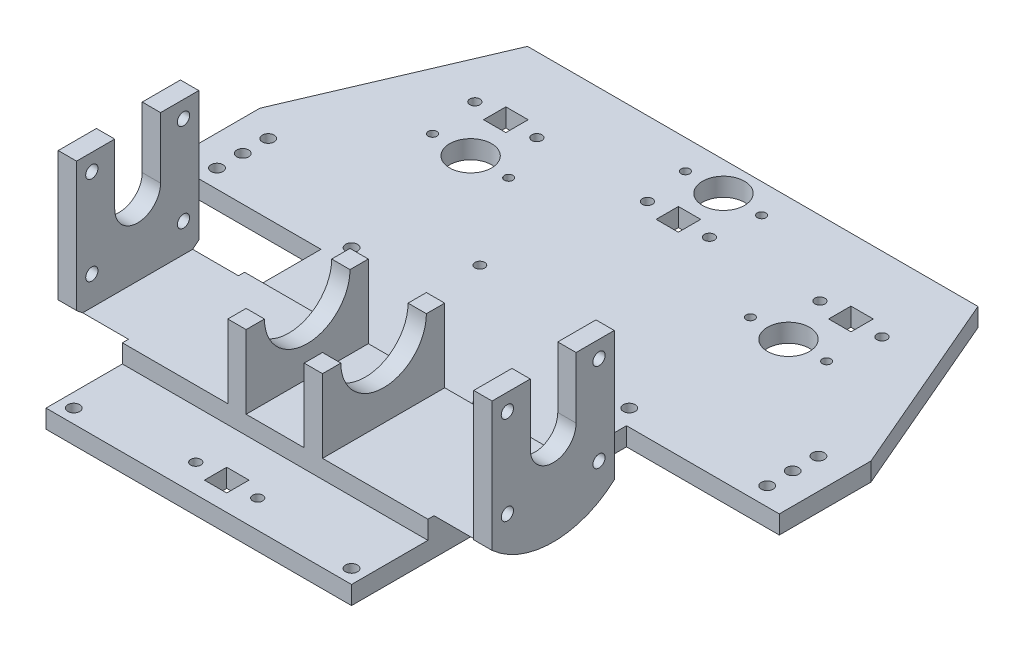
from build123d import *

# Parameters (mm, degrees)
SALIENTE_EXTRUIR1_DEPTH     = 6
CROQUIS2_W                  = 6
CROQUIS2_H                  = 40
SALIENTE_EXTRUIR2_DEPTH     = 50
CORTAR_EXTRUIR1_REACH       = 210.447
CROQUIS3_R                  = 2
CROQUIS4_W                  = 31
CROQUIS4_H                  = 40
SALIENTE_EXTRUIR3_DEPTH     = 30
CORTAR_EXTRUIR2_REACH       = 177.525
CROQUIS5_W                  = 19
CROQUIS5_H                  = 24
CORTAR_EXTRUIR3_DEPTH       = 31
CORTAR_EXTRUIR4_REACH       = 148.714
CORTAR_EXTRUIR5_DEPTH       = 21
CORTAR_EXTRUIR6_DEPTH       = 21
SALIENTE_EXTRUIR8_DEPTH     = 80.5
CORTAR_EXTRUIR7_DEPTH       = 15
CROQUIS18_R                 = 1.95
CORTAR_EXTRUIR31_DEPTH      = 17.5
CROQUIS19_R                 = 3.25
CORTAR_EXTRUIR32_DEPTH      = 2.2
CROQUIS21_R                 = 1.95
CORTAR_EXTRUIR33_DEPTH      = 17.5
CROQUIS22_R                 = 3.25
CORTAR_EXTRUIR34_DEPTH      = 2.2
CROQUIS24_W                 = 8.67512497
CROQUIS24_H                 = 6
CORTAR_EXTRUIR36_DEPTH      = 313.226607494
CORTAR_EXTRUIR36_DEPTH_BACK = 313.226607494
CROQUIS29_R                 = 1.95
CORTAR_EXTRUIR38_DEPTH      = 6
CROQUIS30_R                 = 3.25
CORTAR_EXTRUIR39_DEPTH      = 2.2
CROQUIS33_W                 = 7.3
CROQUIS33_H                 = 7.3
CORTAR_EXTRUIR42_DEPTH      = 6
CROQUIS34_R                 = 1.65
CORTAR_EXTRUIR43_DEPTH      = 5
CROQUIS35_R                 = 6.875
CORTAR_EXTRUIR44_DEPTH      = 6
CROQUIS38_R                 = 1.6
CORTAR_EXTRUIR46_DEPTH      = 4.5
CROQUIS39_R                 = 1.4
CORTAR_EXTRUIR47_DEPTH      = 6


with BuildPart() as part:
    # Croquis1 → Saliente-Extruir1 (new body)
    with BuildSketch(Plane(origin=(0, 16, 0), x_dir=(1, 0, 0), z_dir=(0, 1, 0))):
        Polygon((100, 95), (-100, 95), (-100, -5), (-50, -5), (-50, -30), (-71, -30), (-71, -70), (-50, -70), (-50, -95), (50, -95), (50, -70), (71, -70), (71, -30), (50, -30), (50, -5), (100, -5), align=None)
    extrude(amount=SALIENTE_EXTRUIR1_DEPTH)

    # Croquis2 → Saliente-Extruir2 (add)
    with BuildSketch(Plane(origin=(0, 22, 0), x_dir=(1, 0, 0), z_dir=(0, 1, 0))):
        with Locations((-68, -50)):
            Rectangle(CROQUIS2_W, CROQUIS2_H)
        with Locations((68, -50)):
            Rectangle(CROQUIS2_W, CROQUIS2_H)
    extrude(amount=SALIENTE_EXTRUIR2_DEPTH)

    # Croquis3 → Cortar-Extruir1 (cut, up to next)
    with BuildSketch(Plane.ZY.offset(71), mode=Mode.PRIVATE) as cortar_extruir1_sk1:
        with Locations((35, 66.5)):
            Circle(CROQUIS3_R)
    cortar_extruir1_tool1 = extrude(cortar_extruir1_sk1.sketch, amount=-CORTAR_EXTRUIR1_REACH, mode=Mode.PRIVATE) & part.part
    # Croquis3 → Cortar-Extruir1 (cut, up to next)
    with BuildSketch(Plane.ZY.offset(71), mode=Mode.PRIVATE) as cortar_extruir1_sk2:
        with Locations((35, 37.5)):
            Circle(CROQUIS3_R)
    cortar_extruir1_tool2 = extrude(cortar_extruir1_sk2.sketch, amount=-CORTAR_EXTRUIR1_REACH, mode=Mode.PRIVATE) & part.part
    # Croquis3 → Cortar-Extruir1 (cut, up to next)
    with BuildSketch(Plane.ZY.offset(71), mode=Mode.PRIVATE) as cortar_extruir1_sk3:
        with Locations((65, 66.5)):
            Circle(CROQUIS3_R)
    cortar_extruir1_tool3 = extrude(cortar_extruir1_sk3.sketch, amount=-CORTAR_EXTRUIR1_REACH, mode=Mode.PRIVATE) & part.part
    # Croquis3 → Cortar-Extruir1 (cut, up to next)
    with BuildSketch(Plane.ZY.offset(71), mode=Mode.PRIVATE) as cortar_extruir1_sk4:
        with Locations((65, 37.5)):
            Circle(CROQUIS3_R)
    cortar_extruir1_tool4 = extrude(cortar_extruir1_sk4.sketch, amount=-CORTAR_EXTRUIR1_REACH, mode=Mode.PRIVATE) & part.part
    # Croquis3 → Cortar-Extruir1 (cut, up to next)
    with BuildSketch(Plane.ZY.offset(71), mode=Mode.PRIVATE) as cortar_extruir1_sk5:
        with BuildLine():
            Line((57.5, 72), (42.5, 72))
            Line((42.5, 72), (42.5, 52))
            ThreePointArc((42.5, 52), (50, 44.5), (57.5, 52))
            Line((57.5, 52), (57.5, 72))
        make_face()
    cortar_extruir1_tool5 = extrude(cortar_extruir1_sk5.sketch, amount=-CORTAR_EXTRUIR1_REACH, mode=Mode.PRIVATE) & part.part
    cortar_extruir1_1 = cortar_extruir1_tool1.solids().sort_by_distance((-71, 66.5, 35))[0]
    add(cortar_extruir1_1, mode=Mode.SUBTRACT)
    cortar_extruir1_2 = cortar_extruir1_tool2.solids().sort_by_distance((-71, 37.5, 35))[0]
    add(cortar_extruir1_2, mode=Mode.SUBTRACT)
    cortar_extruir1_3 = cortar_extruir1_tool3.solids().sort_by_distance((-71, 66.5, 65))[0]
    add(cortar_extruir1_3, mode=Mode.SUBTRACT)
    cortar_extruir1_4 = cortar_extruir1_tool4.solids().sort_by_distance((-71, 37.5, 65))[0]
    add(cortar_extruir1_4, mode=Mode.SUBTRACT)
    cortar_extruir1_5 = cortar_extruir1_tool5.solids().sort_by_distance((-71, 59.000641, 50))[0]
    add(cortar_extruir1_5, mode=Mode.SUBTRACT)
    cortar_extruir1 = cortar_extruir1_1 + cortar_extruir1_2 + cortar_extruir1_3 + cortar_extruir1_4 + cortar_extruir1_5  # Cortar-Extruir1 as one shape, for the pattern or mirror that repeats it

    # Simetr_a1: Cortar-Extruir1 across plane
    add(cortar_extruir1.mirror(Plane(origin=(0, 0, 0), x_dir=(0, 0, 1), z_dir=(1, 0, 0))), mode=Mode.SUBTRACT)

    # Croquis4 → Saliente-Extruir3 (add)
    with BuildSketch(Plane(origin=(0, 22, 0), x_dir=(1, 0, 0), z_dir=(0, 1, 0))):
        with Locations((0, -50)):
            Rectangle(CROQUIS4_W, CROQUIS4_H)
    extrude(amount=SALIENTE_EXTRUIR3_DEPTH)

    # Croquis5 → Cortar-Extruir2 (cut, up to next)
    with BuildSketch(Plane(origin=(0, 0, 30), x_dir=(-1, 0, 0), z_dir=(0, 0, -1)), mode=Mode.PRIVATE) as cortar_extruir2_sk1:
        with Locations((0, 40)):
            Rectangle(CROQUIS5_W, CROQUIS5_H)
    cortar_extruir2_tool1 = extrude(cortar_extruir2_sk1.sketch, amount=-CORTAR_EXTRUIR2_REACH, mode=Mode.PRIVATE) & part.part
    add(cortar_extruir2_tool1.solids().sort_by_distance((0, 40, 30))[0], mode=Mode.SUBTRACT)

    # Croquis6 → Cortar-Extruir3 (cut)
    with BuildSketch(Plane(origin=(15.5, 0, 0), x_dir=(0, 0, -1), z_dir=(1, 0, 0))):
        with BuildLine():
            Line((-64, 52), (-36, 52))
            ThreePointArc((-36, 52), (-50, 38), (-64, 52))
        make_face()
    extrude(amount=-CORTAR_EXTRUIR3_DEPTH, mode=Mode.SUBTRACT)

    # Croquis9 → Cortar-Extruir4 (cut, up to next)
    with BuildSketch(Plane(origin=(0, 22, 0), x_dir=(1, 0, 0), z_dir=(0, 1, 0)), mode=Mode.PRIVATE) as cortar_extruir4_sk1:
        Polygon((100, 25), (70, 95), (100, 95), align=None)
    cortar_extruir4_tool1 = extrude(cortar_extruir4_sk1.sketch, amount=-CORTAR_EXTRUIR4_REACH, mode=Mode.PRIVATE) & part.part
    # Croquis9 → Cortar-Extruir4 (cut, up to next)
    with BuildSketch(Plane(origin=(0, 22, 0), x_dir=(1, 0, 0), z_dir=(0, 1, 0)), mode=Mode.PRIVATE) as cortar_extruir4_sk2:
        Polygon((-70, 95), (-100, 95), (-100, 25), align=None)
    cortar_extruir4_tool2 = extrude(cortar_extruir4_sk2.sketch, amount=-CORTAR_EXTRUIR4_REACH, mode=Mode.PRIVATE) & part.part
    add(cortar_extruir4_tool1.solids().sort_by_distance((90, 22, -71.666667))[0], mode=Mode.SUBTRACT)
    add(cortar_extruir4_tool2.solids().sort_by_distance((-90, 22, -71.666667))[0], mode=Mode.SUBTRACT)

    # Croquis10 → Cortar-Extruir5 (cut)
    with BuildSketch(Plane.ZY.offset(71)):
        with BuildLine():
            Line((70, 16), (70, 17.358983849))
            ThreePointArc((70, 17.358983849), (68.730127256, 16.65622639), (67.435595774, 16))
            Line((67.435595774, 16), (70, 16))
        make_face()
        with BuildLine():
            ThreePointArc((32.564404226, 16), (31.269872744, 16.65622639), (30, 17.358983849))
            Line((30, 17.358983849), (30, 16))
            Line((30, 16), (32.564404226, 16))
        make_face()
        with BuildLine():
            Line((30, 25.751190503), (30, 17.358983849))
            ThreePointArc((30, 17.358983849), (31.269872744, 16.65622639), (32.564404226, 16))
            Line((32.564404226, 16), (67.435595774, 16))
            ThreePointArc((67.435595774, 16), (68.730127256, 16.65622639), (70, 17.358983849))
            Line((70, 17.358983849), (70, 25.751190503))
            ThreePointArc((70, 25.751190503), (50, 19), (30, 25.751190503))
        make_face()
        with BuildLine():
            Line((30, 29.639320225), (30, 25.751190503))
            ThreePointArc((30, 25.751190503), (50, 19), (70, 25.751190503))
            Line((70, 25.751190503), (70, 29.639320225))
            ThreePointArc((70, 29.639320225), (50, 22), (30, 29.639320225))
        make_face()
        with BuildLine():
            ThreePointArc((83, 52), (35.354181484, 81.571946165), (30, 25.751190503))
            Line((30, 25.751190503), (30, 29.639320225))
            ThreePointArc((30, 29.639320225), (37.752551286, 79.386127875), (80, 52))
            ThreePointArc((80, 52), (77.386127875, 39.752551286), (70, 29.639320225))
            Line((70, 29.639320225), (70, 25.751190503))
            ThreePointArc((70, 25.751190503), (79.571946165, 37.354181484), (83, 52))
        make_face()
        with BuildLine():
            Line((30, 29.639320225), (30, 25.751190503))
            ThreePointArc((30, 25.751190503), (50, 19), (70, 25.751190503))
            Line((70, 25.751190503), (70, 29.639320225))
            ThreePointArc((70, 29.639320225), (50, 22), (30, 29.639320225))
        make_face()
        with BuildLine():
            ThreePointArc((83, 52), (35.354181484, 81.571946165), (30, 25.751190503))
            Line((30, 25.751190503), (30, 29.639320225))
            ThreePointArc((30, 29.639320225), (37.752551286, 79.386127875), (80, 52))
            ThreePointArc((80, 52), (77.386127875, 39.752551286), (70, 29.639320225))
            Line((70, 29.639320225), (70, 25.751190503))
            ThreePointArc((70, 25.751190503), (79.571946165, 37.354181484), (83, 52))
        make_face()
    extrude(amount=-CORTAR_EXTRUIR5_DEPTH, mode=Mode.SUBTRACT)


with BuildPart() as cortar_extruir5_piece_1:
    # of the separate pieces the step leaves, piece 1, a body of its own (cortar_extruir5_pieces)
    add(part.part.solids().sort_by_distance((50, 16, 95))[0])

    # Croquis11 → Cortar-Extruir6 (cut)
    with BuildSketch(Plane(origin=(71, 0, 0), x_dir=(0, 0, -1), z_dir=(1, 0, 0))):
        with BuildLine():
            ThreePointArc((-67.435595774, 16), (-68.730127256, 16.65622639), (-70, 17.358983849))
            Line((-70, 17.358983849), (-70, 16))
            Line((-70, 16), (-67.435595774, 16))
        make_face()
        with BuildLine():
            ThreePointArc((-20, 52), (-22.613872125, 39.752551286), (-30, 29.639320225))
            Line((-30, 29.639320225), (-30, 25.751190503))
            ThreePointArc((-30, 25.751190503), (-20.428053835, 37.354181484), (-17, 52))
            ThreePointArc((-17, 52), (-64.645818516, 81.571946165), (-70, 25.751190503))
            Line((-70, 25.751190503), (-70, 29.639320225))
            ThreePointArc((-70, 29.639320225), (-62.247448714, 79.386127875), (-20, 52))
        make_face()
        with BuildLine():
            Line((-30, 25.751190503), (-30, 29.639320225))
            ThreePointArc((-30, 29.639320225), (-50, 22), (-70, 29.639320225))
            Line((-70, 29.639320225), (-70, 25.751190503))
            ThreePointArc((-70, 25.751190503), (-50, 19), (-30, 25.751190503))
        make_face()
        with BuildLine():
            Line((-30, 17.358983849), (-30, 25.751190503))
            ThreePointArc((-30, 25.751190503), (-50, 19), (-70, 25.751190503))
            Line((-70, 25.751190503), (-70, 17.358983849))
            ThreePointArc((-70, 17.358983849), (-68.730127256, 16.65622639), (-67.435595774, 16))
            Line((-67.435595774, 16), (-32.564404226, 16))
            ThreePointArc((-32.564404226, 16), (-31.269872744, 16.65622639), (-30, 17.358983849))
        make_face()
        with BuildLine():
            Line((-30, 16), (-30, 17.358983849))
            ThreePointArc((-30, 17.358983849), (-31.269872744, 16.65622639), (-32.564404226, 16))
            Line((-32.564404226, 16), (-30, 16))
        make_face()
    extrude(amount=-CORTAR_EXTRUIR6_DEPTH, mode=Mode.SUBTRACT)


with BuildPart() as cortar_extruir5_piece_2:
    # of the separate pieces the step leaves, piece 2, a body of its own (cortar_extruir5_pieces)
    add(part.part.solids().sort_by_distance((-71, 29.639320225, 70))[0])



with BuildPart() as cortar_extruir6_piece_1:
    # of the separate pieces the step leaves, piece 1, a body of its own (cortar_extruir6_pieces)
    add(cortar_extruir5_piece_1.part.solids().sort_by_distance((50, 16, 95))[0])


with BuildPart() as cortar_extruir6_piece_2:
    # of the separate pieces the step leaves, piece 2, a body of its own (cortar_extruir6_pieces)
    add(cortar_extruir5_piece_1.part.solids().sort_by_distance((71, 29.639320225, 70))[0])


with BuildPart() as cortar_extruir5_piece_2_1:
    add(cortar_extruir5_piece_2.part)

    add(cortar_extruir6_piece_1.part)  # Saliente-Extruir8 merges Cortar-Extruir6 piece 1
    # Croquis13 → Saliente-Extruir8 (add)
    with BuildSketch(Plane(origin=(-65, 0, 0), x_dir=(0, 0, -1), z_dir=(1, 0, 0))):
        with BuildLine():
            Line((-68, 28), (-70, 28))
            Line((-70, 28), (-70, 22))
            Line((-70, 22), (-50, 22))
            ThreePointArc((-50, 22), (-59.486832981, 23.539501058), (-68, 28))
        make_face()
        with BuildLine():
            Line((-32, 28), (-68, 28))
            ThreePointArc((-68, 28), (-59.486832981, 23.539501058), (-50, 22))
            ThreePointArc((-50, 22), (-40.513167019, 23.539501058), (-32, 28))
        make_face()
        with BuildLine():
            Line((-30, 22), (-30, 28))
            Line((-30, 28), (-32, 28))
            ThreePointArc((-32, 28), (-40.513167019, 23.539501058), (-50, 22))
            Line((-50, 22), (-30, 22))
        make_face()
    saliente_extruir8 = extrude(amount=SALIENTE_EXTRUIR8_DEPTH)

    # Simetr_a10: Saliente-Extruir8 across plane
    add(saliente_extruir8.mirror(Plane(origin=(0, 0, 0), x_dir=(0, 0, 1), z_dir=(1, 0, 0))))

    # Croquis14 → Cortar-Extruir7 (cut)
    with BuildSketch(Plane.ZY.offset(65)):
        with BuildLine():
            Line((70, 22), (70, 28))
            Line((70, 28), (68, 28))
            ThreePointArc((68, 28), (59.486832981, 23.539501058), (50, 22))
            Line((50, 22), (70, 22))
        make_face()
        with BuildLine():
            Line((30, 22), (50, 22))
            ThreePointArc((50, 22), (40.513167019, 23.539501058), (32, 28))
            Line((32, 28), (30, 28))
            Line((30, 28), (30, 22))
        make_face()
    cortar_extruir7 = extrude(amount=-CORTAR_EXTRUIR7_DEPTH, mode=Mode.SUBTRACT)

    # Simetr_a12: Cortar-Extruir7 across plane
    add(cortar_extruir7.mirror(Plane(origin=(0, 0, 0), x_dir=(0, 0, 1), z_dir=(1, 0, 0))), mode=Mode.SUBTRACT)

    # Croquis18 → Cortar-Extruir31 (cut)
    with BuildSketch(Plane.XZ.offset(-16)):
        with Locations(Location((-45.45, 90.45, 0), (0, 0, 270))):
            Circle(CROQUIS18_R)
    cortar_extruir31 = extrude(amount=-CORTAR_EXTRUIR31_DEPTH, mode=Mode.SUBTRACT)

    # Croquis19 → Cortar-Extruir32 (cut)
    with BuildSketch(Plane.XZ.offset(-16)):
        with Locations(Location((-45.45, 90.45, 0), (0, 0, 270))):
            Circle(CROQUIS19_R)
    cortar_extruir32 = extrude(amount=-CORTAR_EXTRUIR32_DEPTH, mode=Mode.SUBTRACT)

    # Simetr_a13: Cortar-Extruir31, Cortar-Extruir32 across plane
    add(cortar_extruir31.mirror(Plane(origin=(0, 0, 0), x_dir=(0, 0, 1), z_dir=(1, 0, 0))), mode=Mode.SUBTRACT)
    add(cortar_extruir32.mirror(Plane(origin=(0, 0, 0), x_dir=(0, 0, 1), z_dir=(1, 0, 0))), mode=Mode.SUBTRACT)

    # Croquis21 → Cortar-Extruir33 (cut)
    with BuildSketch(Plane.XZ.offset(-16)):
        with Locations(Location((45.45, -0.45, 0), (0, 0, 270))):
            Circle(CROQUIS21_R)
        with Locations(Location((-45.45, -0.45, 0), (0, 0, 270))):
            Circle(CROQUIS21_R)
    extrude(amount=-CORTAR_EXTRUIR33_DEPTH, mode=Mode.SUBTRACT)

    # Croquis22 → Cortar-Extruir34 (cut)
    with BuildSketch(Plane.XZ.offset(-16)):
        with Locations(Location((45.45, -0.45, 0), (0, 0, 270))):
            Circle(CROQUIS22_R)
        with Locations(Location((-45.45, -0.45, 0), (0, 0, 270))):
            Circle(CROQUIS22_R)
    extrude(amount=-CORTAR_EXTRUIR34_DEPTH, mode=Mode.SUBTRACT)

    # Croquis24 → Cortar-Extruir36 (cut, two sides)
    with BuildSketch(Plane(origin=(4.580542105, 14.193676317, -193.455878052), x_dir=(0, 0, -1), z_dir=(1, 0, 0))) as cortar_extruir36_sk:
        with Locations((-102.793440537, 4.806323683)):
            Rectangle(CROQUIS24_W, CROQUIS24_H)
    extrude(amount=CORTAR_EXTRUIR36_DEPTH, mode=Mode.SUBTRACT)
    extrude(cortar_extruir36_sk.sketch, amount=-CORTAR_EXTRUIR36_DEPTH_BACK, mode=Mode.SUBTRACT)

    # Croquis29 → Cortar-Extruir38 (cut)
    with BuildSketch(Plane.XZ.offset(-16)):
        with Locations(Location((90.042254279, -17.77, 0), (0, 0, 270))):
            Circle(CROQUIS29_R)
        with Locations(Location((90, -9.385, 0), (0, 0, 270))):
            Circle(CROQUIS29_R)
        with Locations(Location((90.042254279, -1, 0), (0, 0, 270))):
            Circle(CROQUIS29_R)
        with Locations(Location((-90.042254279, -1, 0), (0, 0, 90))):
            Circle(CROQUIS29_R)
        with Locations(Location((-90, -9.385, 0), (0, 0, 90))):
            Circle(CROQUIS29_R)
        with Locations(Location((-90.042254279, -17.77, 0), (0, 0, 90))):
            Circle(CROQUIS29_R)
    extrude(amount=-CORTAR_EXTRUIR38_DEPTH, mode=Mode.SUBTRACT)

    # Croquis30 → Cortar-Extruir39 (cut)
    with BuildSketch(Plane.XZ.offset(-16)):
        with Locations(Location((90.073577236, -1, 0), (0, 0, 270))):
            Circle(CROQUIS30_R)
        with Locations(Location((90, -9.385, 0), (0, 0, 270))):
            Circle(CROQUIS30_R)
        with Locations(Location((90, -17.768453788, 0), (0, 0, 270))):
            Circle(CROQUIS30_R)
        with Locations(Location((-90, -17.768453788, 0), (0, 0, 90))):
            Circle(CROQUIS30_R)
        with Locations(Location((-90, -9.385, 0), (0, 0, 90))):
            Circle(CROQUIS30_R)
        with Locations(Location((-90.073577236, -1, 0), (0, 0, 90))):
            Circle(CROQUIS30_R)
    extrude(amount=-CORTAR_EXTRUIR39_DEPTH, mode=Mode.SUBTRACT)

    # Croquis33 → Cortar-Extruir42 (cut)
    with BuildSketch(Plane(origin=(0, 22, 0), x_dir=(1, 0, 0), z_dir=(0, 1, 0))):
        with Locations((-56.473903104, 61.98267988)):
            Rectangle(CROQUIS33_W, CROQUIS33_H)
        with Locations((0, 61.98267988)):
            Rectangle(CROQUIS33_W, CROQUIS33_H)
        with Locations((56.473903104, 61.98267988)):
            Rectangle(CROQUIS33_W, CROQUIS33_H)
        with Locations((0, -85.85)):
            Rectangle(CROQUIS33_W, CROQUIS33_H)
    extrude(amount=-CORTAR_EXTRUIR42_DEPTH, mode=Mode.SUBTRACT)

    # Croquis34 → Cortar-Extruir43 (cut)
    with BuildSketch(Plane(origin=(0, 22, 0), x_dir=(1, 0, 0), z_dir=(0, 1, 0))):
        with Locations(Location((46.323903104, 61.98267988, 0), (0, 0, 270))):
            Circle(CROQUIS34_R)
        with Locations(Location((66.623903104, 61.98267988, 0), (0, 0, 270))):
            Circle(CROQUIS34_R)
        with Locations(Location((10.15, -85.85, 0), (0, 0, 270))):
            Circle(CROQUIS34_R)
        with Locations(Location((-10.15, -85.85, 0), (0, 0, 270))):
            Circle(CROQUIS34_R)
        with Locations(Location((10.15, 61.98267988, 0), (0, 0, 270))):
            Circle(CROQUIS34_R)
        with Locations(Location((-10.15, 61.98267988, 0), (0, 0, 270))):
            Circle(CROQUIS34_R)
        with Locations(Location((-46.323903104, 61.98267988, 0), (0, 0, 270))):
            Circle(CROQUIS34_R)
        with Locations(Location((-66.623903104, 61.98267988, 0), (0, 0, 270))):
            Circle(CROQUIS34_R)
    extrude(amount=-CORTAR_EXTRUIR43_DEPTH, mode=Mode.SUBTRACT)

    # Croquis35 → Cortar-Extruir44 (cut)
    with BuildSketch(Plane(origin=(0, 22, 0), x_dir=(1, 0, 0), z_dir=(0, 1, 0))):
        with Locations(Location((0, 76.746276418, 0), (0, 0, 270))):
            Circle(CROQUIS35_R)
        with Locations(Location((-52.019276555, 45.994416346, 0), (0, 0, 270))):
            Circle(CROQUIS35_R)
        with Locations(Location((52.019276555, 45.994416346, 0), (0, 0, 270))):
            Circle(CROQUIS35_R)
    extrude(amount=-CORTAR_EXTRUIR44_DEPTH, mode=Mode.SUBTRACT)

    # Croquis38 → Cortar-Extruir46 (cut)
    with BuildSketch(Plane(origin=(0, 22, 0), x_dir=(1, 0, 0), z_dir=(0, 1, 0))):
        with Locations(Location((19.5, 16.5, 0), (0, 0, 270))):
            Circle(CROQUIS38_R)
        with Locations(Location((-19.5, 16.5, 0), (0, 0, 270))):
            Circle(CROQUIS38_R)
        with Locations(Location((-19.5, -22.5, 0), (0, 0, 270))):
            Circle(CROQUIS38_R)
        with Locations(Location((19.5, -22.5, 0), (0, 0, 270))):
            Circle(CROQUIS38_R)
    extrude(amount=-CORTAR_EXTRUIR46_DEPTH, mode=Mode.SUBTRACT)

    # Croquis39 → Cortar-Extruir47 (cut)
    with BuildSketch(Plane(origin=(0, 22, 0), x_dir=(1, 0, 0), z_dir=(0, 1, 0))):
        with Locations(Location((-64.484276555, 45.994416346, 0), (0, 0, 270))):
            Circle(CROQUIS39_R)
        with Locations(Location((-39.554276555, 45.994416346, 0), (0, 0, 270))):
            Circle(CROQUIS39_R)
        with Locations(Location((12.465, 76.746276418, 0), (0, 0, 270))):
            Circle(CROQUIS39_R)
        with Locations(Location((-12.465, 76.746276418, 0), (0, 0, 270))):
            Circle(CROQUIS39_R)
        with Locations(Location((39.554276555, 45.994416346, 0), (0, 0, 270))):
            Circle(CROQUIS39_R)
        with Locations(Location((64.484276555, 45.994416346, 0), (0, 0, 270))):
            Circle(CROQUIS39_R)
    extrude(amount=-CORTAR_EXTRUIR47_DEPTH, mode=Mode.SUBTRACT)


solid = Compound([cortar_extruir6_piece_2.part, cortar_extruir5_piece_2_1.part])
